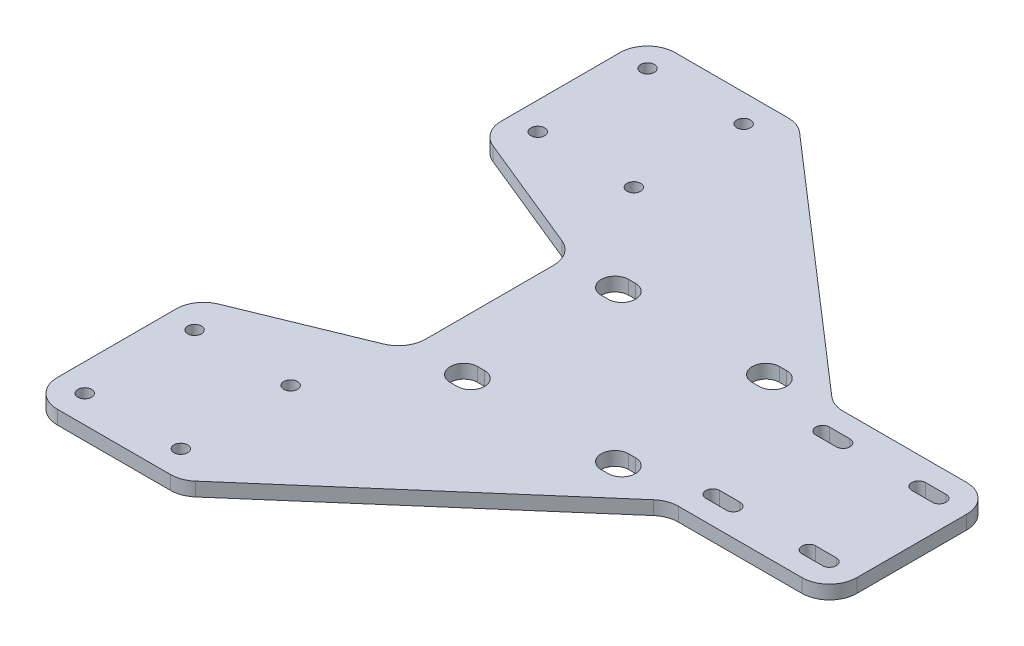
from build123d import *

# Parameters (mm, degrees)
ESQUISSE1_W             = 83.5
ESQUISSE1_H             = 90
BOSS_EXTRU_1_DEPTH      = 2
ESQUISSE2_R             = 1
ENL_V_MAT_EXTRU_1_DEPTH = 3
CONG_1_R                = 4
ENL_V_MAT_EXTRU_2_DEPTH = 3


with BuildPart() as part:
    # Esquisse1 → Boss.-Extru.1 (new body)
    with BuildSketch(Plane(origin=(0, 0, 0), x_dir=(1, 0, 0), z_dir=(0, 1, 0))):
        Rectangle(ESQUISSE1_W, ESQUISSE1_H)
    extrude(amount=BOSS_EXTRU_1_DEPTH)

    # Esquisse2 → Enlèv. mat.-Extru.1 (cut, through all)
    with BuildSketch(Plane(origin=(0, 0, 0), x_dir=(1, 0, 0), z_dir=(0, 1, 0))):
        with Locations((-23.75, -25)):
            Circle(ESQUISSE2_R)
        with Locations((-37.75, -25)):
            Circle(ESQUISSE2_R)
        with Locations((-37.75, -41)):
            Circle(ESQUISSE2_R)
        with Locations((-23.75, -41)):
            Circle(ESQUISSE2_R)
        with Locations((-23.75, 41)):
            Circle(ESQUISSE2_R)
        with Locations((-37.75, 41)):
            Circle(ESQUISSE2_R)
        with Locations((-37.75, 25)):
            Circle(ESQUISSE2_R)
        with Locations((-23.75, 25)):
            Circle(ESQUISSE2_R)
        Polygon((41.75, 12), (18.25, 12), (-19.75, 45), (41.75, 45), align=None)
        Polygon((41.75, -12), (18.25, -12), (-19.75, -45), (41.75, -45), align=None)
        Polygon((-41.75, -21), (-19.75, -12), (-19.75, 12), (-41.75, 21), align=None)
        with BuildLine():
            Line((20.75, 9), (23.75, 9))
            ThreePointArc((23.75, 9), (24.75, 8), (23.75, 7))
            Line((23.75, 7), (20.75, 7))
            ThreePointArc((20.75, 7), (19.75, 8), (20.75, 9))
        make_face()
        with BuildLine():
            Line((37.75, 7), (34.75, 7))
            ThreePointArc((34.75, 7), (33.75, 8), (34.75, 9))
            Line((34.75, 9), (37.75, 9))
            ThreePointArc((37.75, 9), (38.75, 8), (37.75, 7))
        make_face()
        with BuildLine():
            Line((20.75, -7), (23.75, -7))
            ThreePointArc((23.75, -7), (24.75, -8), (23.75, -9))
            Line((23.75, -9), (20.75, -9))
            ThreePointArc((20.75, -9), (19.75, -8), (20.75, -7))
        make_face()
        with BuildLine():
            Line((37.75, -9), (34.75, -9))
            ThreePointArc((34.75, -9), (33.75, -8), (34.75, -7))
            Line((34.75, -7), (37.75, -7))
            ThreePointArc((37.75, -7), (38.75, -8), (37.75, -9))
        make_face()
    extrude(amount=ENL_V_MAT_EXTRU_1_DEPTH, mode=Mode.SUBTRACT)

    # Congé1
    cong_1_edges = [part.edges().sort_by_distance(p)[0] for p in [
        (-19.75, 1, -12),
        (-41.75, 1, -45),
        (-41.75, 1, 45),
        (41.75, 1, 12),
        (18.25, 1, 12),
        (-19.75, 1, 45),
        (41.75, 1, -12),
        (-19.75, 1, -45),
        (18.25, 1, -12),
        (-41.75, 1, -21),
        (-41.75, 1, 21),
        (-19.75, 1, 12),
    ]]
    fillet(cong_1_edges, radius=CONG_1_R)

    # Esquisse3 → Enlèv. mat.-Extru.2 (cut, through all)
    with BuildSketch(Plane(origin=(0, 0, 0), x_dir=(1, 0, 0), z_dir=(0, 1, 0))):
        with BuildLine():
            Line((-12.5, 13), (-11.5, 13))
            ThreePointArc((-11.5, 13), (-9.5, 11), (-11.5, 9))
            Line((-11.5, 9), (-12.5, 9))
            ThreePointArc((-12.5, 9), (-14.5, 11), (-12.5, 13))
        make_face()
        with BuildLine():
            Line((10.5, 13), (9.5, 13))
            ThreePointArc((9.5, 13), (7.5, 11), (9.5, 9))
            Line((9.5, 9), (10.5, 9))
            ThreePointArc((10.5, 9), (12.5, 11), (10.5, 13))
        make_face()
        with BuildLine():
            Line((10.5, -13), (9.5, -13))
            ThreePointArc((9.5, -13), (7.5, -11), (9.5, -9))
            Line((9.5, -9), (10.5, -9))
            ThreePointArc((10.5, -9), (12.5, -11), (10.5, -13))
        make_face()
        with BuildLine():
            Line((-12.5, -13), (-11.5, -13))
            ThreePointArc((-11.5, -13), (-9.5, -11), (-11.5, -9))
            Line((-11.5, -9), (-12.5, -9))
            ThreePointArc((-12.5, -9), (-14.5, -11), (-12.5, -13))
        make_face()
    extrude(amount=ENL_V_MAT_EXTRU_2_DEPTH, mode=Mode.SUBTRACT)


solid = part.part
